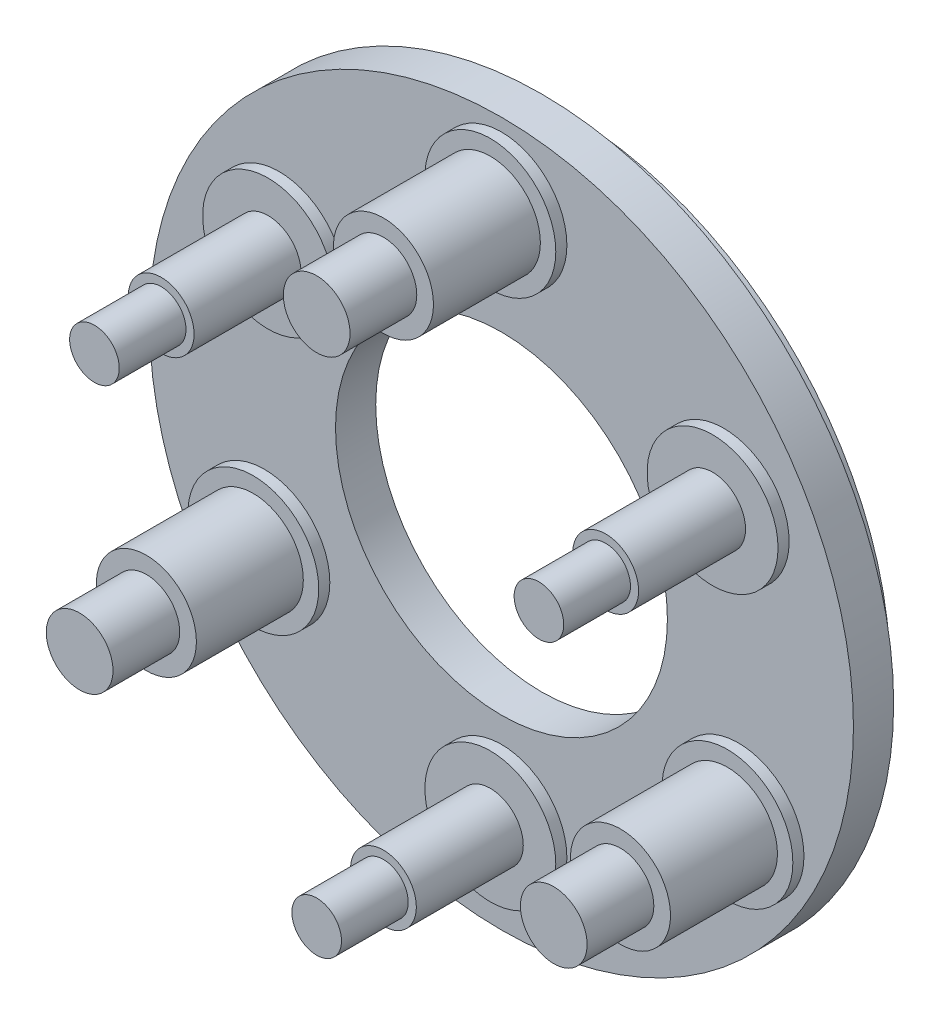
from build123d import *

# Parameters (mm, degrees)
SKETCH1_R         = 10.4521
SKETCH1_R_2       = 4.9276
BASE_DEPTH        = 1.1938
SKETCH2_R         = 9.6393
SKETCH2_R_2       = 8.89
TRACK_DEPTH       = 0.7112
SKETCH3_R         = 1.9431
PLATFORM_1_DEPTH  = 0.3302
SKETCH4_R         = 1.4859
SKETCH4_R_2       = 0.9779
PLATFORM_2_DEPTH  = 3.175
SKETCH5_R         = 0.9906
SKETCH5_R_2       = 0.7366
PLATFORM_3_DEPTH  = 1.9812
CIRPATTERN1_COUNT = 3


with BuildPart() as part:
    # Sketch1 → Base (new body)
    with BuildSketch(Plane.XY):
        Circle(SKETCH1_R)
        Circle(SKETCH1_R_2, mode=Mode.SUBTRACT)
    extrude(amount=BASE_DEPTH)

    # Sketch2 → Track (add)
    with BuildSketch(Plane(origin=(0, 0, 0), x_dir=(-1, 0, 0), z_dir=(0, 0, -1))):
        Circle(SKETCH2_R)
        Circle(SKETCH2_R_2, mode=Mode.SUBTRACT)
    extrude(amount=TRACK_DEPTH)

    # Sketch3 → Platform 1 (add)
    with BuildSketch(Plane.XY.offset(1.1938)):
        with Locations((0, 8.128)):
            Circle(SKETCH3_R)
        with Locations((0, -7.62)):
            Circle(SKETCH3_R)
    platform_1 = extrude(amount=PLATFORM_1_DEPTH)

    # Sketch4 → Platform 2 (add)
    with BuildSketch(Plane.XY.offset(1.524)):
        with Locations((0, 8.128)):
            Circle(SKETCH4_R)
        with Locations((0, -7.62)):
            Circle(SKETCH4_R_2)
    platform_2 = extrude(amount=PLATFORM_2_DEPTH)

    # Sketch5 → Platform 3 (add)
    with BuildSketch(Plane.XY.offset(4.699)):
        with Locations((0, 8.128)):
            Circle(SKETCH5_R)
        with Locations((0, -7.62)):
            Circle(SKETCH5_R_2)
    platform_3 = extrude(amount=PLATFORM_3_DEPTH)

    # CirPattern1: Platform 1, Platform 2, Platform 3 ×3 about axis
    cirpattern1_axis = Axis((0, 0, 0), (0, 0, 1))
    for i in range(1, CIRPATTERN1_COUNT):
        add(platform_1.rotate(cirpattern1_axis, i * 360 / CIRPATTERN1_COUNT))
        add(platform_2.rotate(cirpattern1_axis, i * 360 / CIRPATTERN1_COUNT))
        add(platform_3.rotate(cirpattern1_axis, i * 360 / CIRPATTERN1_COUNT))


solid = part.part
